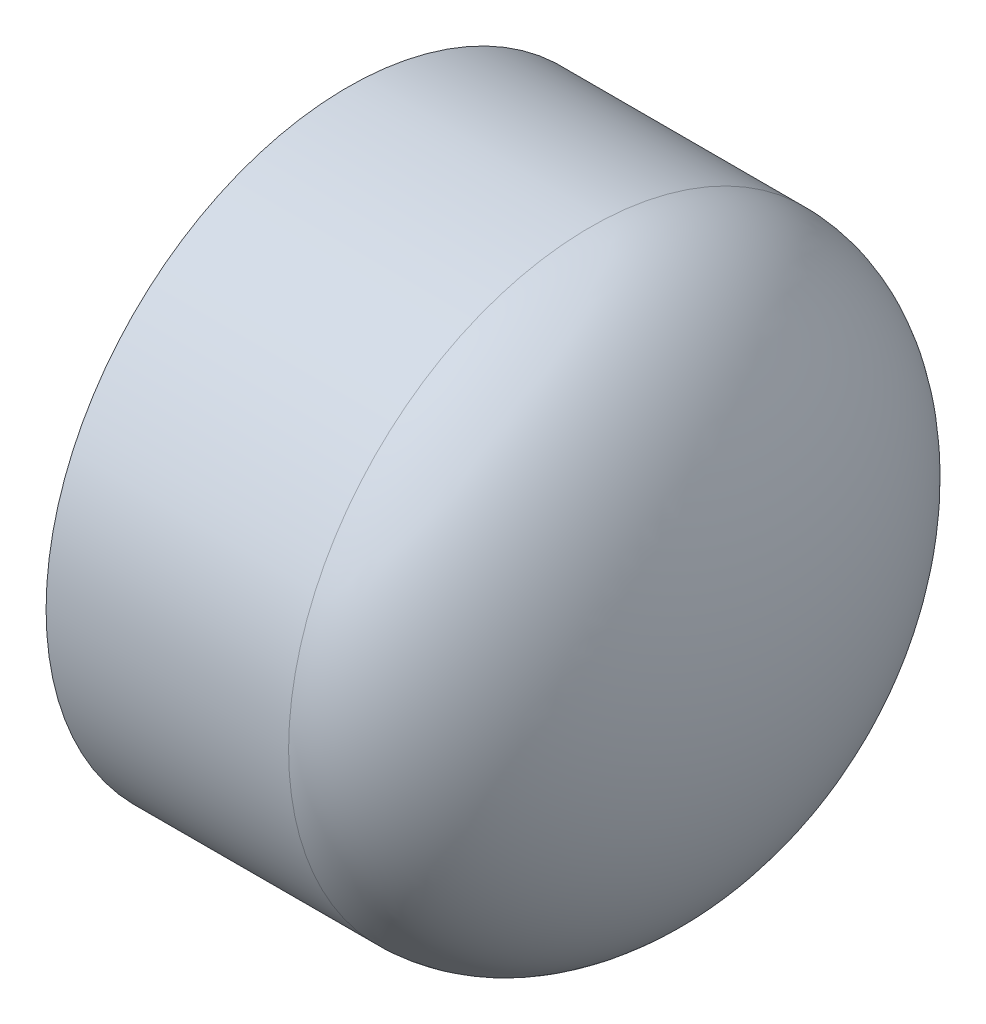
from build123d import *


with BuildPart() as part:
    # Sketch1 → Revolve1 (revolve)
    with BuildSketch(Plane.XY):
        with BuildLine():
            Line((37.6174, 0), (44.3992, 0))
            add(Edge.make_bspline(
                [(6.9088, -63.8175), (44.3992, -63.8175), (44.3992, 0)],
                knots=[3.141592654, 3.141592654, 3.141592654, 4.71238898, 4.71238898, 4.71238898], degree=2, weights=[1, 0.707106781, 1]))
            Line((6.9088, -63.8175), (-44.3992, -63.8175))
            Line((-44.3992, -63.8175), (-44.3992, -57.3786))
            Line((-44.3992, -57.3786), (6.9088, -57.0357))
            add(Edge.make_bspline(
                [(6.9088, -57.0357), (37.6174, -57.0357), (37.6174, 0)],
                knots=[0, 0, 0, 1.570796327, 1.570796327, 1.570796327], degree=2, weights=[1, 0.707106781, 1]))
        make_face()
    revolve(axis=Axis((-44.3992, 0, 0), (1, 0, 0)))


solid = part.part
